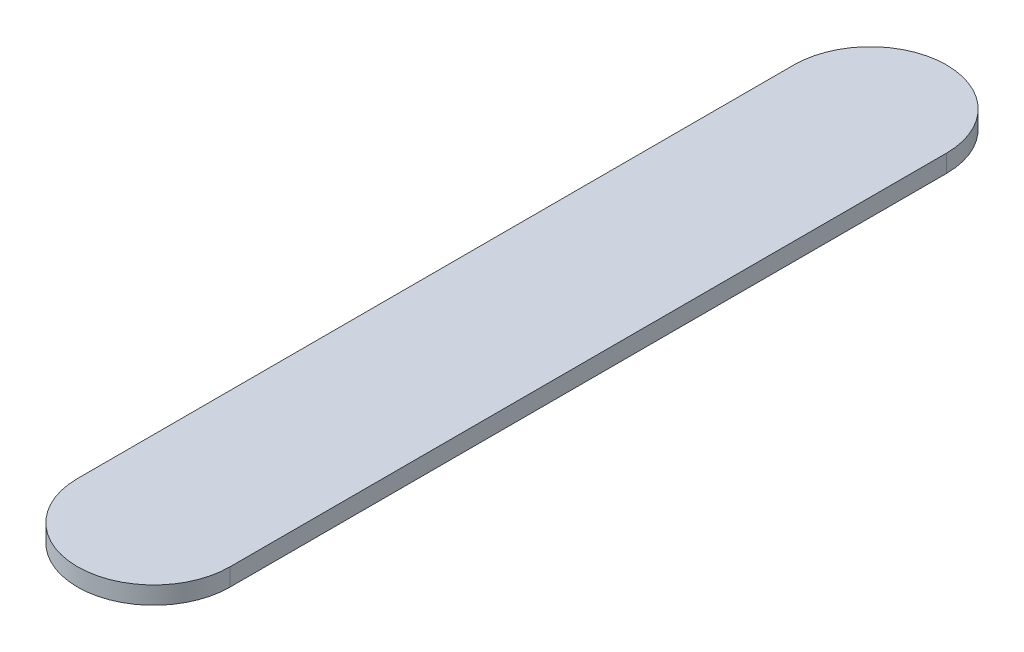
from build123d import *

# Parameters (mm, degrees)
EXTRUDE_1_DEPTH = 1.5


with BuildPart() as part:
    # 草图1 → 凸台-拉伸1 (new body)
    with BuildSketch(Plane(origin=(0, 0, 0), x_dir=(1, 0, 0), z_dir=(0, 1, 0))):
        with BuildLine():
            Line((-6.5, 30.5), (-6.5, -30.5))
            ThreePointArc((-6.5, -30.5), (0, -37), (6.5, -30.5))
            Line((6.5, -30.5), (6.5, 30.5))
            ThreePointArc((6.5, 30.5), (0, 37), (-6.5, 30.5))
        make_face()
    extrude(amount=EXTRUDE_1_DEPTH)


solid = part.part
